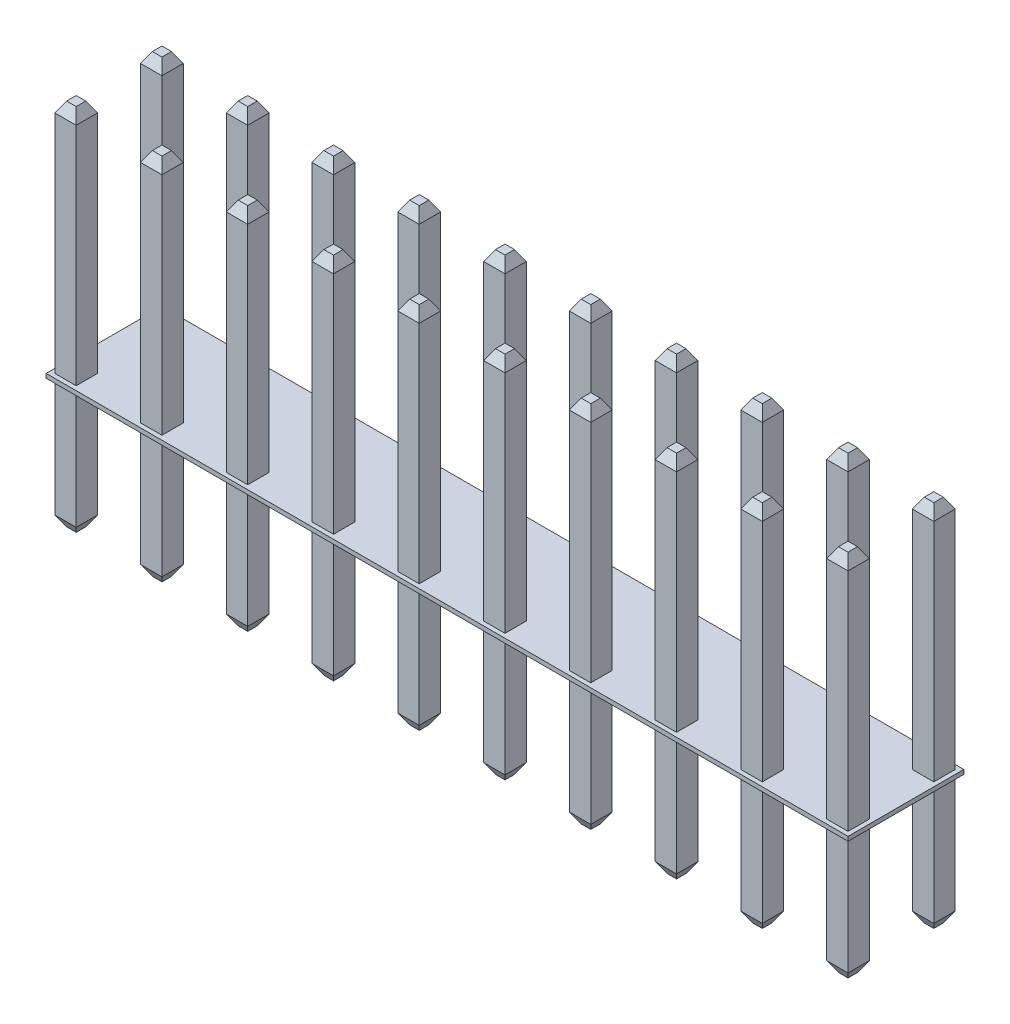
from build123d import *

# Parameters (mm, degrees)
SKETCH1_W              = 23.749
SKETCH1_H              = 3.429
BOSS_EXTRUDE1_DEPTH    = 0.127
SKETCH2_W              = 0.635
SKETCH2_H              = 0.635
BOSS_EXTRUDE2_DEPTH    = 6.985
SKETCH3_W              = 0.635
SKETCH3_H              = 0.635
BOSS_EXTRUDE3_DEPTH    = 6.985
SKETCH4_W              = 0.635
SKETCH4_H              = 0.635
BOSS_EXTRUDE4_DEPTH    = 6.985
SKETCH5_W              = 0.635
SKETCH5_H              = 0.635
BOSS_EXTRUDE5_DEPTH    = 6.985
SKETCH6_W              = 0.635
SKETCH6_H              = 0.635
BOSS_EXTRUDE6_DEPTH    = 6.985
SKETCH7_W              = 0.635
SKETCH7_H              = 0.635
BOSS_EXTRUDE7_DEPTH    = 6.985
SKETCH8_W              = 0.635
SKETCH8_H              = 0.635
BOSS_EXTRUDE8_DEPTH    = 6.985
SKETCH9_W              = 0.635
SKETCH9_H              = 0.635
BOSS_EXTRUDE9_DEPTH    = 6.985
SKETCH10_W             = 0.635
SKETCH10_H             = 0.635
BOSS_EXTRUDE10_DEPTH   = 3.81
SKETCH11_W             = 0.635
SKETCH11_H             = 0.635
BOSS_EXTRUDE11_DEPTH   = 3.81
SKETCH12_W             = 0.635
SKETCH12_H             = 0.635
BOSS_EXTRUDE12_DEPTH   = 3.81
SKETCH13_W             = 0.635
SKETCH13_H             = 0.635
BOSS_EXTRUDE13_DEPTH   = 3.81
SKETCH14_W             = 0.635
SKETCH14_H             = 0.635
BOSS_EXTRUDE14_DEPTH   = 3.81
SKETCH15_W             = 0.635
SKETCH15_H             = 0.635
BOSS_EXTRUDE15_DEPTH   = 3.81
SKETCH16_W             = 0.635
SKETCH16_H             = 0.635
BOSS_EXTRUDE16_DEPTH   = 3.81
SKETCH17_W             = 0.635
SKETCH17_H             = 0.635
BOSS_EXTRUDE17_DEPTH   = 3.81
SKETCH18_W             = 0.635
SKETCH18_H             = 0.635
BOSS_EXTRUDE18_DEPTH   = 3.81
SKETCH19_W             = 0.635
SKETCH19_H             = 0.635
BOSS_EXTRUDE19_DEPTH   = 3.81
SKETCH20_W             = 0.635
SKETCH20_H             = 0.635
BOSS_EXTRUDE20_DEPTH   = 3.81
SKETCH21_W             = 0.635
SKETCH21_H             = 0.635
BOSS_EXTRUDE21_DEPTH   = 3.81
SKETCH22_W             = 0.635
SKETCH22_H             = 0.635
BOSS_EXTRUDE22_DEPTH   = 3.81
SKETCH23_W             = 0.635
SKETCH23_H             = 0.635
BOSS_EXTRUDE23_DEPTH   = 3.81
SKETCH24_W             = 0.635
SKETCH24_H             = 0.635
BOSS_EXTRUDE24_DEPTH   = 3.81
SKETCH25_W             = 0.635
SKETCH25_H             = 0.635
BOSS_EXTRUDE25_DEPTH   = 3.81
SKETCH26_W             = 0.635
SKETCH26_H             = 0.635
BOSS_EXTRUDE26_DEPTH   = 3.81
SKETCH27_W             = 0.635
SKETCH27_H             = 0.635
BOSS_EXTRUDE27_DEPTH   = 3.81
SKETCH28_W             = 0.635
SKETCH28_H             = 0.635
BOSS_EXTRUDE28_DEPTH   = 3.81
SKETCH29_W             = 0.635
SKETCH29_H             = 0.635
BOSS_EXTRUDE29_DEPTH   = 3.81
SKETCH30_W             = 0.635
SKETCH30_H             = 0.635
BOSS_EXTRUDE30_DEPTH   = 6.985
SKETCH31_W             = 0.635
SKETCH31_H             = 0.635
BOSS_EXTRUDE31_DEPTH   = 6.985
SKETCH32_W             = 0.635
SKETCH32_H             = 0.635
BOSS_EXTRUDE32_DEPTH   = 6.985
SKETCH33_W             = 0.635
SKETCH33_H             = 0.635
BOSS_EXTRUDE33_DEPTH   = 6.985
SKETCH34_W             = 0.635
SKETCH34_H             = 0.635
BOSS_EXTRUDE34_DEPTH   = 6.985
SKETCH35_W             = 0.635
SKETCH35_H             = 0.635
BOSS_EXTRUDE35_DEPTH   = 6.985
SKETCH36_W             = 0.635
SKETCH36_H             = 0.635
BOSS_EXTRUDE36_DEPTH   = 6.985
SKETCH37_W             = 0.635
SKETCH37_H             = 0.635
BOSS_EXTRUDE37_DEPTH   = 6.985
SKETCH38_W             = 0.635
SKETCH38_H             = 0.635
BOSS_EXTRUDE38_DEPTH   = 6.985
SKETCH39_W             = 0.635
SKETCH39_H             = 0.635
BOSS_EXTRUDE39_DEPTH   = 6.985
SKETCH40_W             = 0.635
SKETCH40_H             = 0.635
BOSS_EXTRUDE40_DEPTH   = 6.985
SKETCH41_W             = 0.635
SKETCH41_H             = 0.635
BOSS_EXTRUDE41_DEPTH   = 6.985
CHAMFER1_SIZE          = 0.175976362
CHAMFER1_SIZE2         = 0.3048
CHAMFER1_PART_2_SIZE   = 0.175976362
CHAMFER1_PART_2_SIZE2  = 0.3048
CHAMFER1_PART_3_SIZE   = 0.175976362
CHAMFER1_PART_3_SIZE2  = 0.3048
CHAMFER1_PART_4_SIZE   = 0.175976362
CHAMFER1_PART_4_SIZE2  = 0.3048
CHAMFER1_PART_5_SIZE   = 0.175976362
CHAMFER1_PART_5_SIZE2  = 0.3048
CHAMFER1_PART_6_SIZE   = 0.175976362
CHAMFER1_PART_6_SIZE2  = 0.3048
CHAMFER1_PART_7_SIZE   = 0.175976362
CHAMFER1_PART_7_SIZE2  = 0.3048
CHAMFER1_PART_8_SIZE   = 0.175976362
CHAMFER1_PART_8_SIZE2  = 0.3048
CHAMFER1_PART_9_SIZE   = 0.175976362
CHAMFER1_PART_9_SIZE2  = 0.3048
CHAMFER1_PART_10_SIZE  = 0.175976362
CHAMFER1_PART_10_SIZE2 = 0.3048
CHAMFER1_PART_11_SIZE  = 0.175976362
CHAMFER1_PART_11_SIZE2 = 0.3048
CHAMFER1_PART_12_SIZE  = 0.175976362
CHAMFER1_PART_12_SIZE2 = 0.3048
CHAMFER1_PART_13_SIZE  = 0.175976362
CHAMFER1_PART_13_SIZE2 = 0.3048
CHAMFER1_PART_14_SIZE  = 0.175976362
CHAMFER1_PART_14_SIZE2 = 0.3048
CHAMFER1_PART_15_SIZE  = 0.175976362
CHAMFER1_PART_15_SIZE2 = 0.3048
CHAMFER1_PART_16_SIZE  = 0.175976362
CHAMFER1_PART_16_SIZE2 = 0.3048
CHAMFER1_PART_17_SIZE  = 0.175976362
CHAMFER1_PART_17_SIZE2 = 0.3048
CHAMFER1_PART_18_SIZE  = 0.175976362
CHAMFER1_PART_18_SIZE2 = 0.3048
CHAMFER1_PART_19_SIZE  = 0.175976362
CHAMFER1_PART_19_SIZE2 = 0.3048
CHAMFER1_PART_20_SIZE  = 0.175976362
CHAMFER1_PART_20_SIZE2 = 0.3048
CHAMFER1_PART_21_SIZE  = 0.175976362
CHAMFER1_PART_21_SIZE2 = 0.3048
CHAMFER1_PART_22_SIZE  = 0.175976362
CHAMFER1_PART_22_SIZE2 = 0.3048
CHAMFER1_PART_23_SIZE  = 0.175976362
CHAMFER1_PART_23_SIZE2 = 0.3048
CHAMFER1_PART_24_SIZE  = 0.175976362
CHAMFER1_PART_24_SIZE2 = 0.3048
CHAMFER1_PART_25_SIZE  = 0.175976362
CHAMFER1_PART_25_SIZE2 = 0.3048
CHAMFER1_PART_26_SIZE  = 0.175976362
CHAMFER1_PART_26_SIZE2 = 0.3048
CHAMFER1_PART_27_SIZE  = 0.175976362
CHAMFER1_PART_27_SIZE2 = 0.3048
CHAMFER1_PART_28_SIZE  = 0.175976362
CHAMFER1_PART_28_SIZE2 = 0.3048
CHAMFER1_PART_29_SIZE  = 0.175976362
CHAMFER1_PART_29_SIZE2 = 0.3048
CHAMFER1_PART_30_SIZE  = 0.175976362
CHAMFER1_PART_30_SIZE2 = 0.3048
CHAMFER1_PART_31_SIZE  = 0.175976362
CHAMFER1_PART_31_SIZE2 = 0.3048
CHAMFER1_PART_32_SIZE  = 0.175976362
CHAMFER1_PART_32_SIZE2 = 0.3048
CHAMFER1_PART_33_SIZE  = 0.175976362
CHAMFER1_PART_33_SIZE2 = 0.3048
CHAMFER1_PART_34_SIZE  = 0.175976362
CHAMFER1_PART_34_SIZE2 = 0.3048
CHAMFER1_PART_35_SIZE  = 0.175976362
CHAMFER1_PART_35_SIZE2 = 0.3048
CHAMFER1_PART_36_SIZE  = 0.175976362
CHAMFER1_PART_36_SIZE2 = 0.3048
CHAMFER1_PART_37_SIZE  = 0.175976362
CHAMFER1_PART_37_SIZE2 = 0.3048
CHAMFER1_PART_38_SIZE  = 0.175976362
CHAMFER1_PART_38_SIZE2 = 0.3048
CHAMFER1_PART_39_SIZE  = 0.175976362
CHAMFER1_PART_39_SIZE2 = 0.3048
CHAMFER1_PART_40_SIZE  = 0.175976362
CHAMFER1_PART_40_SIZE2 = 0.3048


with BuildPart() as part:
    # Sketch1 → Boss-Extrude1 (new body)
    with BuildSketch(Plane(origin=(0, 3.937, 0), x_dir=(1, 0, 0), z_dir=(0, 1, 0))):
        Rectangle(SKETCH1_W, SKETCH1_H)
    extrude(amount=-BOSS_EXTRUDE1_DEPTH)

    # Sketch2 → Boss-Extrude2 (add)
    with BuildSketch(Plane(origin=(0, 3.937, 0), x_dir=(-1, 0, 0), z_dir=(0, 1, 0))):
        with Locations((8.89, -1.27)):
            Rectangle(SKETCH2_W, SKETCH2_H)
    extrude(amount=BOSS_EXTRUDE2_DEPTH)

    # Sketch3 → Boss-Extrude3 (add)
    with BuildSketch(Plane(origin=(0, 3.937, 0), x_dir=(-1, 0, 0), z_dir=(0, 1, 0))):
        with Locations((6.35, -1.27)):
            Rectangle(SKETCH3_W, SKETCH3_H)
    extrude(amount=BOSS_EXTRUDE3_DEPTH)

    # Sketch4 → Boss-Extrude4 (add)
    with BuildSketch(Plane(origin=(0, 3.937, 0), x_dir=(-1, 0, 0), z_dir=(0, 1, 0))):
        with Locations((3.81, -1.27)):
            Rectangle(SKETCH4_W, SKETCH4_H)
    extrude(amount=BOSS_EXTRUDE4_DEPTH)

    # Sketch5 → Boss-Extrude5 (add)
    with BuildSketch(Plane(origin=(0, 3.937, 0), x_dir=(-1, 0, 0), z_dir=(0, 1, 0))):
        with Locations((1.27, -1.27)):
            Rectangle(SKETCH5_W, SKETCH5_H)
    extrude(amount=BOSS_EXTRUDE5_DEPTH)

    # Sketch6 → Boss-Extrude6 (add)
    with BuildSketch(Plane(origin=(0, 3.937, 0), x_dir=(-1, 0, 0), z_dir=(0, 1, 0))):
        with Locations((-1.27, -1.27)):
            Rectangle(SKETCH6_W, SKETCH6_H)
    extrude(amount=BOSS_EXTRUDE6_DEPTH)

    # Sketch7 → Boss-Extrude7 (add)
    with BuildSketch(Plane(origin=(0, 3.937, 0), x_dir=(-1, 0, 0), z_dir=(0, 1, 0))):
        with Locations((-3.81, -1.27)):
            Rectangle(SKETCH7_W, SKETCH7_H)
    extrude(amount=BOSS_EXTRUDE7_DEPTH)

    # Sketch8 → Boss-Extrude8 (add)
    with BuildSketch(Plane(origin=(0, 3.937, 0), x_dir=(-1, 0, 0), z_dir=(0, 1, 0))):
        with Locations((-6.35, -1.27)):
            Rectangle(SKETCH8_W, SKETCH8_H)
    extrude(amount=BOSS_EXTRUDE8_DEPTH)

    # Sketch9 → Boss-Extrude9 (add)
    with BuildSketch(Plane(origin=(0, 3.937, 0), x_dir=(-1, 0, 0), z_dir=(0, 1, 0))):
        with Locations((-8.89, -1.27)):
            Rectangle(SKETCH9_W, SKETCH9_H)
    extrude(amount=BOSS_EXTRUDE9_DEPTH)

    # Sketch10 → Boss-Extrude10 (add)
    with BuildSketch(Plane.XZ.offset(-3.81)):
        with Locations((11.43, -1.27)):
            Rectangle(SKETCH10_W, SKETCH10_H)
    extrude(amount=BOSS_EXTRUDE10_DEPTH)

    # Sketch11 → Boss-Extrude11 (add)
    with BuildSketch(Plane.XZ.offset(-3.81)):
        with Locations((8.89, -1.27)):
            Rectangle(SKETCH11_W, SKETCH11_H)
    extrude(amount=BOSS_EXTRUDE11_DEPTH)

    # Sketch12 → Boss-Extrude12 (add)
    with BuildSketch(Plane.XZ.offset(-3.81)):
        with Locations((6.35, -1.27)):
            Rectangle(SKETCH12_W, SKETCH12_H)
    extrude(amount=BOSS_EXTRUDE12_DEPTH)

    # Sketch13 → Boss-Extrude13 (add)
    with BuildSketch(Plane.XZ.offset(-3.81)):
        with Locations((3.81, -1.27)):
            Rectangle(SKETCH13_W, SKETCH13_H)
    extrude(amount=BOSS_EXTRUDE13_DEPTH)

    # Sketch14 → Boss-Extrude14 (add)
    with BuildSketch(Plane.XZ.offset(-3.81)):
        with Locations((1.27, -1.27)):
            Rectangle(SKETCH14_W, SKETCH14_H)
    extrude(amount=BOSS_EXTRUDE14_DEPTH)

    # Sketch15 → Boss-Extrude15 (add)
    with BuildSketch(Plane.XZ.offset(-3.81)):
        with Locations((-1.27, -1.27)):
            Rectangle(SKETCH15_W, SKETCH15_H)
    extrude(amount=BOSS_EXTRUDE15_DEPTH)

    # Sketch16 → Boss-Extrude16 (add)
    with BuildSketch(Plane.XZ.offset(-3.81)):
        with Locations((-3.81, -1.27)):
            Rectangle(SKETCH16_W, SKETCH16_H)
    extrude(amount=BOSS_EXTRUDE16_DEPTH)

    # Sketch17 → Boss-Extrude17 (add)
    with BuildSketch(Plane.XZ.offset(-3.81)):
        with Locations((-6.35, -1.27)):
            Rectangle(SKETCH17_W, SKETCH17_H)
    extrude(amount=BOSS_EXTRUDE17_DEPTH)

    # Sketch18 → Boss-Extrude18 (add)
    with BuildSketch(Plane.XZ.offset(-3.81)):
        with Locations((-8.89, -1.27)):
            Rectangle(SKETCH18_W, SKETCH18_H)
    extrude(amount=BOSS_EXTRUDE18_DEPTH)

    # Sketch19 → Boss-Extrude19 (add)
    with BuildSketch(Plane.XZ.offset(-3.81)):
        with Locations((-11.43, -1.27)):
            Rectangle(SKETCH19_W, SKETCH19_H)
    extrude(amount=BOSS_EXTRUDE19_DEPTH)

    # Sketch20 → Boss-Extrude20 (add)
    with BuildSketch(Plane.XZ.offset(-3.81)):
        with Locations((-11.43, 1.27)):
            Rectangle(SKETCH20_W, SKETCH20_H)
    extrude(amount=BOSS_EXTRUDE20_DEPTH)

    # Sketch21 → Boss-Extrude21 (add)
    with BuildSketch(Plane.XZ.offset(-3.81)):
        with Locations((-8.89, 1.27)):
            Rectangle(SKETCH21_W, SKETCH21_H)
    extrude(amount=BOSS_EXTRUDE21_DEPTH)

    # Sketch22 → Boss-Extrude22 (add)
    with BuildSketch(Plane.XZ.offset(-3.81)):
        with Locations((-6.35, 1.27)):
            Rectangle(SKETCH22_W, SKETCH22_H)
    extrude(amount=BOSS_EXTRUDE22_DEPTH)

    # Sketch23 → Boss-Extrude23 (add)
    with BuildSketch(Plane.XZ.offset(-3.81)):
        with Locations((-3.81, 1.27)):
            Rectangle(SKETCH23_W, SKETCH23_H)
    extrude(amount=BOSS_EXTRUDE23_DEPTH)

    # Sketch24 → Boss-Extrude24 (add)
    with BuildSketch(Plane.XZ.offset(-3.81)):
        with Locations((-1.27, 1.27)):
            Rectangle(SKETCH24_W, SKETCH24_H)
    extrude(amount=BOSS_EXTRUDE24_DEPTH)

    # Sketch25 → Boss-Extrude25 (add)
    with BuildSketch(Plane.XZ.offset(-3.81)):
        with Locations((1.27, 1.27)):
            Rectangle(SKETCH25_W, SKETCH25_H)
    extrude(amount=BOSS_EXTRUDE25_DEPTH)

    # Sketch26 → Boss-Extrude26 (add)
    with BuildSketch(Plane.XZ.offset(-3.81)):
        with Locations((3.81, 1.27)):
            Rectangle(SKETCH26_W, SKETCH26_H)
    extrude(amount=BOSS_EXTRUDE26_DEPTH)

    # Sketch27 → Boss-Extrude27 (add)
    with BuildSketch(Plane.XZ.offset(-3.81)):
        with Locations((6.35, 1.27)):
            Rectangle(SKETCH27_W, SKETCH27_H)
    extrude(amount=BOSS_EXTRUDE27_DEPTH)

    # Sketch28 → Boss-Extrude28 (add)
    with BuildSketch(Plane.XZ.offset(-3.81)):
        with Locations((8.89, 1.27)):
            Rectangle(SKETCH28_W, SKETCH28_H)
    extrude(amount=BOSS_EXTRUDE28_DEPTH)

    # Sketch29 → Boss-Extrude29 (add)
    with BuildSketch(Plane.XZ.offset(-3.81)):
        with Locations((11.43, 1.27)):
            Rectangle(SKETCH29_W, SKETCH29_H)
    extrude(amount=BOSS_EXTRUDE29_DEPTH)

    # Sketch30 → Boss-Extrude30 (add)
    with BuildSketch(Plane(origin=(0, 3.937, 0), x_dir=(-1, 0, 0), z_dir=(0, 1, 0))):
        with Locations((-11.43, 1.27)):
            Rectangle(SKETCH30_W, SKETCH30_H)
    extrude(amount=BOSS_EXTRUDE30_DEPTH)

    # Sketch31 → Boss-Extrude31 (add)
    with BuildSketch(Plane(origin=(0, 3.937, 0), x_dir=(-1, 0, 0), z_dir=(0, 1, 0))):
        with Locations((-8.89, 1.27)):
            Rectangle(SKETCH31_W, SKETCH31_H)
    extrude(amount=BOSS_EXTRUDE31_DEPTH)

    # Sketch32 → Boss-Extrude32 (add)
    with BuildSketch(Plane(origin=(0, 3.937, 0), x_dir=(-1, 0, 0), z_dir=(0, 1, 0))):
        with Locations((-6.35, 1.27)):
            Rectangle(SKETCH32_W, SKETCH32_H)
    extrude(amount=BOSS_EXTRUDE32_DEPTH)

    # Sketch33 → Boss-Extrude33 (add)
    with BuildSketch(Plane(origin=(0, 3.937, 0), x_dir=(-1, 0, 0), z_dir=(0, 1, 0))):
        with Locations((-3.81, 1.27)):
            Rectangle(SKETCH33_W, SKETCH33_H)
    extrude(amount=BOSS_EXTRUDE33_DEPTH)

    # Sketch34 → Boss-Extrude34 (add)
    with BuildSketch(Plane(origin=(0, 3.937, 0), x_dir=(-1, 0, 0), z_dir=(0, 1, 0))):
        with Locations((-1.27, 1.27)):
            Rectangle(SKETCH34_W, SKETCH34_H)
    extrude(amount=BOSS_EXTRUDE34_DEPTH)

    # Sketch35 → Boss-Extrude35 (add)
    with BuildSketch(Plane(origin=(0, 3.937, 0), x_dir=(-1, 0, 0), z_dir=(0, 1, 0))):
        with Locations((1.27, 1.27)):
            Rectangle(SKETCH35_W, SKETCH35_H)
    extrude(amount=BOSS_EXTRUDE35_DEPTH)

    # Sketch36 → Boss-Extrude36 (add)
    with BuildSketch(Plane(origin=(0, 3.937, 0), x_dir=(-1, 0, 0), z_dir=(0, 1, 0))):
        with Locations((3.81, 1.27)):
            Rectangle(SKETCH36_W, SKETCH36_H)
    extrude(amount=BOSS_EXTRUDE36_DEPTH)

    # Sketch37 → Boss-Extrude37 (add)
    with BuildSketch(Plane(origin=(0, 3.937, 0), x_dir=(-1, 0, 0), z_dir=(0, 1, 0))):
        with Locations((6.35, 1.27)):
            Rectangle(SKETCH37_W, SKETCH37_H)
    extrude(amount=BOSS_EXTRUDE37_DEPTH)

    # Sketch38 → Boss-Extrude38 (add)
    with BuildSketch(Plane(origin=(0, 3.937, 0), x_dir=(-1, 0, 0), z_dir=(0, 1, 0))):
        with Locations((8.89, 1.27)):
            Rectangle(SKETCH38_W, SKETCH38_H)
    extrude(amount=BOSS_EXTRUDE38_DEPTH)

    # Sketch39 → Boss-Extrude39 (add)
    with BuildSketch(Plane(origin=(0, 3.937, 0), x_dir=(-1, 0, 0), z_dir=(0, 1, 0))):
        with Locations((11.43, -1.27)):
            Rectangle(SKETCH39_W, SKETCH39_H)
    extrude(amount=BOSS_EXTRUDE39_DEPTH)

    # Sketch40 → Boss-Extrude40 (add)
    with BuildSketch(Plane(origin=(0, 3.937, 0), x_dir=(-1, 0, 0), z_dir=(0, 1, 0))):
        with Locations((-11.43, -1.27)):
            Rectangle(SKETCH40_W, SKETCH40_H)
    extrude(amount=BOSS_EXTRUDE40_DEPTH)

    # Sketch41 → Boss-Extrude41 (add)
    with BuildSketch(Plane(origin=(0, 3.937, 0), x_dir=(-1, 0, 0), z_dir=(0, 1, 0))):
        with Locations((11.43, 1.27)):
            Rectangle(SKETCH41_W, SKETCH41_H)
    extrude(amount=BOSS_EXTRUDE41_DEPTH)

    # Chamfer1
    chamfer1_edges = [part.edges().sort_by_distance(p)[0] for p in [
        (6.0325, 10.922, -1.27),
        (6.35, 10.922, -0.9525),
        (6.6675, 10.922, -1.27),
        (6.35, 10.922, -1.5875),
    ]]
    chamfer1_side = [part.faces().sort_by_distance(p)[0] for p in [
        (6.35, 10.922, -1.27),
    ]]
    chamfer(chamfer1_edges, length=CHAMFER1_SIZE, length2=CHAMFER1_SIZE2, reference=chamfer1_side[0])

    # Chamfer1 part 2
    chamfer1_part_2_edges = [part.edges().sort_by_distance(p)[0] for p in [
        (8.5725, 10.922, -1.27),
        (8.89, 10.922, -0.9525),
        (9.2075, 10.922, -1.27),
        (8.89, 10.922, -1.5875),
    ]]
    chamfer1_part_2_side = [part.faces().sort_by_distance(p)[0] for p in [
        (8.89, 10.922, -1.27),
    ]]
    chamfer(chamfer1_part_2_edges, length=CHAMFER1_PART_2_SIZE, length2=CHAMFER1_PART_2_SIZE2, reference=chamfer1_part_2_side[0])

    # Chamfer1 part 3
    chamfer1_part_3_edges = [part.edges().sort_by_distance(p)[0] for p in [
        (11.43, 0, -0.9525),
        (11.1125, 0, -1.27),
        (11.43, 0, -1.5875),
        (11.7475, 0, -1.27),
    ]]
    chamfer1_part_3_side = [part.faces().sort_by_distance(p)[0] for p in [
        (11.43, 0, -1.27),
    ]]
    chamfer(chamfer1_part_3_edges, length=CHAMFER1_PART_3_SIZE, length2=CHAMFER1_PART_3_SIZE2, reference=chamfer1_part_3_side[0])

    # Chamfer1 part 4
    chamfer1_part_4_edges = [part.edges().sort_by_distance(p)[0] for p in [
        (9.2075, 0, -1.27),
        (8.89, 0, -0.9525),
        (8.5725, 0, -1.27),
        (8.89, 0, -1.5875),
    ]]
    chamfer1_part_4_side = [part.faces().sort_by_distance(p)[0] for p in [
        (8.89, 0, -1.27),
    ]]
    chamfer(chamfer1_part_4_edges, length=CHAMFER1_PART_4_SIZE, length2=CHAMFER1_PART_4_SIZE2, reference=chamfer1_part_4_side[0])

    # Chamfer1 part 5
    chamfer1_part_5_edges = [part.edges().sort_by_distance(p)[0] for p in [
        (6.6675, 0, -1.27),
        (6.35, 0, -0.9525),
        (6.0325, 0, -1.27),
        (6.35, 0, -1.5875),
    ]]
    chamfer1_part_5_side = [part.faces().sort_by_distance(p)[0] for p in [
        (6.35, 0, -1.27),
    ]]
    chamfer(chamfer1_part_5_edges, length=CHAMFER1_PART_5_SIZE, length2=CHAMFER1_PART_5_SIZE2, reference=chamfer1_part_5_side[0])

    # Chamfer1 part 6
    chamfer1_part_6_edges = [part.edges().sort_by_distance(p)[0] for p in [
        (4.1275, 0, -1.27),
        (3.81, 0, -0.9525),
        (3.4925, 0, -1.27),
        (3.81, 0, -1.5875),
    ]]
    chamfer1_part_6_side = [part.faces().sort_by_distance(p)[0] for p in [
        (3.81, 0, -1.27),
    ]]
    chamfer(chamfer1_part_6_edges, length=CHAMFER1_PART_6_SIZE, length2=CHAMFER1_PART_6_SIZE2, reference=chamfer1_part_6_side[0])

    # Chamfer1 part 7
    chamfer1_part_7_edges = [part.edges().sort_by_distance(p)[0] for p in [
        (-8.89, 10.922, -0.9525),
        (-8.5725, 10.922, -1.27),
        (-8.89, 10.922, -1.5875),
        (-9.2075, 10.922, -1.27),
    ]]
    chamfer1_part_7_side = [part.faces().sort_by_distance(p)[0] for p in [
        (-8.89, 10.922, -1.27),
    ]]
    chamfer(chamfer1_part_7_edges, length=CHAMFER1_PART_7_SIZE, length2=CHAMFER1_PART_7_SIZE2, reference=chamfer1_part_7_side[0])

    # Chamfer1 part 8
    chamfer1_part_8_edges = [part.edges().sort_by_distance(p)[0] for p in [
        (1.5875, 0, -1.27),
        (1.27, 0, -0.9525),
        (0.9525, 0, -1.27),
        (1.27, 0, -1.5875),
    ]]
    chamfer1_part_8_side = [part.faces().sort_by_distance(p)[0] for p in [
        (1.27, 0, -1.27),
    ]]
    chamfer(chamfer1_part_8_edges, length=CHAMFER1_PART_8_SIZE, length2=CHAMFER1_PART_8_SIZE2, reference=chamfer1_part_8_side[0])

    # Chamfer1 part 9
    chamfer1_part_9_edges = [part.edges().sort_by_distance(p)[0] for p in [
        (-0.9525, 0, -1.27),
        (-1.27, 0, -0.9525),
        (-1.5875, 0, -1.27),
        (-1.27, 0, -1.5875),
    ]]
    chamfer1_part_9_side = [part.faces().sort_by_distance(p)[0] for p in [
        (-1.27, 0, -1.27),
    ]]
    chamfer(chamfer1_part_9_edges, length=CHAMFER1_PART_9_SIZE, length2=CHAMFER1_PART_9_SIZE2, reference=chamfer1_part_9_side[0])

    # Chamfer1 part 10
    chamfer1_part_10_edges = [part.edges().sort_by_distance(p)[0] for p in [
        (-3.4925, 0, -1.27),
        (-3.81, 0, -0.9525),
        (-4.1275, 0, -1.27),
        (-3.81, 0, -1.5875),
    ]]
    chamfer1_part_10_side = [part.faces().sort_by_distance(p)[0] for p in [
        (-3.81, 0, -1.27),
    ]]
    chamfer(chamfer1_part_10_edges, length=CHAMFER1_PART_10_SIZE, length2=CHAMFER1_PART_10_SIZE2, reference=chamfer1_part_10_side[0])

    # Chamfer1 part 11
    chamfer1_part_11_edges = [part.edges().sort_by_distance(p)[0] for p in [
        (-6.0325, 0, -1.27),
        (-6.35, 0, -0.9525),
        (-6.6675, 0, -1.27),
        (-6.35, 0, -1.5875),
    ]]
    chamfer1_part_11_side = [part.faces().sort_by_distance(p)[0] for p in [
        (-6.35, 0, -1.27),
    ]]
    chamfer(chamfer1_part_11_edges, length=CHAMFER1_PART_11_SIZE, length2=CHAMFER1_PART_11_SIZE2, reference=chamfer1_part_11_side[0])

    # Chamfer1 part 12
    chamfer1_part_12_edges = [part.edges().sort_by_distance(p)[0] for p in [
        (-8.5725, 0, -1.27),
        (-8.89, 0, -0.9525),
        (-9.2075, 0, -1.27),
        (-8.89, 0, -1.5875),
    ]]
    chamfer1_part_12_side = [part.faces().sort_by_distance(p)[0] for p in [
        (-8.89, 0, -1.27),
    ]]
    chamfer(chamfer1_part_12_edges, length=CHAMFER1_PART_12_SIZE, length2=CHAMFER1_PART_12_SIZE2, reference=chamfer1_part_12_side[0])

    # Chamfer1 part 13
    chamfer1_part_13_edges = [part.edges().sort_by_distance(p)[0] for p in [
        (-11.1125, 0, -1.27),
        (-11.43, 0, -0.9525),
        (-11.7475, 0, -1.27),
        (-11.43, 0, -1.5875),
    ]]
    chamfer1_part_13_side = [part.faces().sort_by_distance(p)[0] for p in [
        (-11.43, 0, -1.27),
    ]]
    chamfer(chamfer1_part_13_edges, length=CHAMFER1_PART_13_SIZE, length2=CHAMFER1_PART_13_SIZE2, reference=chamfer1_part_13_side[0])

    # Chamfer1 part 14
    chamfer1_part_14_edges = [part.edges().sort_by_distance(p)[0] for p in [
        (-11.7475, 0, 1.27),
        (-11.43, 0, 0.9525),
        (-11.1125, 0, 1.27),
        (-11.43, 0, 1.5875),
    ]]
    chamfer1_part_14_side = [part.faces().sort_by_distance(p)[0] for p in [
        (-11.43, 0, 1.27),
    ]]
    chamfer(chamfer1_part_14_edges, length=CHAMFER1_PART_14_SIZE, length2=CHAMFER1_PART_14_SIZE2, reference=chamfer1_part_14_side[0])

    # Chamfer1 part 15
    chamfer1_part_15_edges = [part.edges().sort_by_distance(p)[0] for p in [
        (-9.2075, 0, 1.27),
        (-8.89, 0, 0.9525),
        (-8.5725, 0, 1.27),
        (-8.89, 0, 1.5875),
    ]]
    chamfer1_part_15_side = [part.faces().sort_by_distance(p)[0] for p in [
        (-8.89, 0, 1.27),
    ]]
    chamfer(chamfer1_part_15_edges, length=CHAMFER1_PART_15_SIZE, length2=CHAMFER1_PART_15_SIZE2, reference=chamfer1_part_15_side[0])

    # Chamfer1 part 16
    chamfer1_part_16_edges = [part.edges().sort_by_distance(p)[0] for p in [
        (-6.6675, 10.922, -1.27),
        (-6.35, 10.922, -0.9525),
        (-6.0325, 10.922, -1.27),
        (-6.35, 10.922, -1.5875),
    ]]
    chamfer1_part_16_side = [part.faces().sort_by_distance(p)[0] for p in [
        (-6.35, 10.922, -1.27),
    ]]
    chamfer(chamfer1_part_16_edges, length=CHAMFER1_PART_16_SIZE, length2=CHAMFER1_PART_16_SIZE2, reference=chamfer1_part_16_side[0])

    # Chamfer1 part 17
    chamfer1_part_17_edges = [part.edges().sort_by_distance(p)[0] for p in [
        (-6.0325, 0, 1.27),
        (-6.35, 0, 1.5875),
        (-6.6675, 0, 1.27),
        (-6.35, 0, 0.9525),
    ]]
    chamfer1_part_17_side = [part.faces().sort_by_distance(p)[0] for p in [
        (-6.35, 0, 1.27),
    ]]
    chamfer(chamfer1_part_17_edges, length=CHAMFER1_PART_17_SIZE, length2=CHAMFER1_PART_17_SIZE2, reference=chamfer1_part_17_side[0])

    # Chamfer1 part 18
    chamfer1_part_18_edges = [part.edges().sort_by_distance(p)[0] for p in [
        (-3.4925, 0, 1.27),
        (-3.81, 0, 1.5875),
        (-4.1275, 0, 1.27),
        (-3.81, 0, 0.9525),
    ]]
    chamfer1_part_18_side = [part.faces().sort_by_distance(p)[0] for p in [
        (-3.81, 0, 1.27),
    ]]
    chamfer(chamfer1_part_18_edges, length=CHAMFER1_PART_18_SIZE, length2=CHAMFER1_PART_18_SIZE2, reference=chamfer1_part_18_side[0])

    # Chamfer1 part 19
    chamfer1_part_19_edges = [part.edges().sort_by_distance(p)[0] for p in [
        (-0.9525, 0, 1.27),
        (-1.27, 0, 1.5875),
        (-1.5875, 0, 1.27),
        (-1.27, 0, 0.9525),
    ]]
    chamfer1_part_19_side = [part.faces().sort_by_distance(p)[0] for p in [
        (-1.27, 0, 1.27),
    ]]
    chamfer(chamfer1_part_19_edges, length=CHAMFER1_PART_19_SIZE, length2=CHAMFER1_PART_19_SIZE2, reference=chamfer1_part_19_side[0])

    # Chamfer1 part 20
    chamfer1_part_20_edges = [part.edges().sort_by_distance(p)[0] for p in [
        (1.5875, 0, 1.27),
        (1.27, 0, 1.5875),
        (0.9525, 0, 1.27),
        (1.27, 0, 0.9525),
    ]]
    chamfer1_part_20_side = [part.faces().sort_by_distance(p)[0] for p in [
        (1.27, 0, 1.27),
    ]]
    chamfer(chamfer1_part_20_edges, length=CHAMFER1_PART_20_SIZE, length2=CHAMFER1_PART_20_SIZE2, reference=chamfer1_part_20_side[0])

    # Chamfer1 part 21
    chamfer1_part_21_edges = [part.edges().sort_by_distance(p)[0] for p in [
        (4.1275, 0, 1.27),
        (3.81, 0, 1.5875),
        (3.4925, 0, 1.27),
        (3.81, 0, 0.9525),
    ]]
    chamfer1_part_21_side = [part.faces().sort_by_distance(p)[0] for p in [
        (3.81, 0, 1.27),
    ]]
    chamfer(chamfer1_part_21_edges, length=CHAMFER1_PART_21_SIZE, length2=CHAMFER1_PART_21_SIZE2, reference=chamfer1_part_21_side[0])

    # Chamfer1 part 22
    chamfer1_part_22_edges = [part.edges().sort_by_distance(p)[0] for p in [
        (6.6675, 0, 1.27),
        (6.35, 0, 1.5875),
        (6.0325, 0, 1.27),
        (6.35, 0, 0.9525),
    ]]
    chamfer1_part_22_side = [part.faces().sort_by_distance(p)[0] for p in [
        (6.35, 0, 1.27),
    ]]
    chamfer(chamfer1_part_22_edges, length=CHAMFER1_PART_22_SIZE, length2=CHAMFER1_PART_22_SIZE2, reference=chamfer1_part_22_side[0])

    # Chamfer1 part 23
    chamfer1_part_23_edges = [part.edges().sort_by_distance(p)[0] for p in [
        (9.2075, 0, 1.27),
        (8.89, 0, 1.5875),
        (8.5725, 0, 1.27),
        (8.89, 0, 0.9525),
    ]]
    chamfer1_part_23_side = [part.faces().sort_by_distance(p)[0] for p in [
        (8.89, 0, 1.27),
    ]]
    chamfer(chamfer1_part_23_edges, length=CHAMFER1_PART_23_SIZE, length2=CHAMFER1_PART_23_SIZE2, reference=chamfer1_part_23_side[0])

    # Chamfer1 part 24
    chamfer1_part_24_edges = [part.edges().sort_by_distance(p)[0] for p in [
        (11.7475, 0, 1.27),
        (11.43, 0, 1.5875),
        (11.1125, 0, 1.27),
        (11.43, 0, 0.9525),
    ]]
    chamfer1_part_24_side = [part.faces().sort_by_distance(p)[0] for p in [
        (11.43, 0, 1.27),
    ]]
    chamfer(chamfer1_part_24_edges, length=CHAMFER1_PART_24_SIZE, length2=CHAMFER1_PART_24_SIZE2, reference=chamfer1_part_24_side[0])

    # Chamfer1 part 25
    chamfer1_part_25_edges = [part.edges().sort_by_distance(p)[0] for p in [
        (11.1125, 10.922, 1.27),
        (11.43, 10.922, 1.5875),
        (11.7475, 10.922, 1.27),
        (11.43, 10.922, 0.9525),
    ]]
    chamfer1_part_25_side = [part.faces().sort_by_distance(p)[0] for p in [
        (11.43, 10.922, 1.27),
    ]]
    chamfer(chamfer1_part_25_edges, length=CHAMFER1_PART_25_SIZE, length2=CHAMFER1_PART_25_SIZE2, reference=chamfer1_part_25_side[0])

    # Chamfer1 part 26
    chamfer1_part_26_edges = [part.edges().sort_by_distance(p)[0] for p in [
        (8.5725, 10.922, 1.27),
        (8.89, 10.922, 1.5875),
        (9.2075, 10.922, 1.27),
        (8.89, 10.922, 0.9525),
    ]]
    chamfer1_part_26_side = [part.faces().sort_by_distance(p)[0] for p in [
        (8.89, 10.922, 1.27),
    ]]
    chamfer(chamfer1_part_26_edges, length=CHAMFER1_PART_26_SIZE, length2=CHAMFER1_PART_26_SIZE2, reference=chamfer1_part_26_side[0])

    # Chamfer1 part 27
    chamfer1_part_27_edges = [part.edges().sort_by_distance(p)[0] for p in [
        (-4.1275, 10.922, -1.27),
        (-3.81, 10.922, -0.9525),
        (-3.4925, 10.922, -1.27),
        (-3.81, 10.922, -1.5875),
    ]]
    chamfer1_part_27_side = [part.faces().sort_by_distance(p)[0] for p in [
        (-3.81, 10.922, -1.27),
    ]]
    chamfer(chamfer1_part_27_edges, length=CHAMFER1_PART_27_SIZE, length2=CHAMFER1_PART_27_SIZE2, reference=chamfer1_part_27_side[0])

    # Chamfer1 part 28
    chamfer1_part_28_edges = [part.edges().sort_by_distance(p)[0] for p in [
        (6.0325, 10.922, 1.27),
        (6.35, 10.922, 1.5875),
        (6.6675, 10.922, 1.27),
        (6.35, 10.922, 0.9525),
    ]]
    chamfer1_part_28_side = [part.faces().sort_by_distance(p)[0] for p in [
        (6.35, 10.922, 1.27),
    ]]
    chamfer(chamfer1_part_28_edges, length=CHAMFER1_PART_28_SIZE, length2=CHAMFER1_PART_28_SIZE2, reference=chamfer1_part_28_side[0])

    # Chamfer1 part 29
    chamfer1_part_29_edges = [part.edges().sort_by_distance(p)[0] for p in [
        (3.4925, 10.922, 1.27),
        (3.81, 10.922, 1.5875),
        (4.1275, 10.922, 1.27),
        (3.81, 10.922, 0.9525),
    ]]
    chamfer1_part_29_side = [part.faces().sort_by_distance(p)[0] for p in [
        (3.81, 10.922, 1.27),
    ]]
    chamfer(chamfer1_part_29_edges, length=CHAMFER1_PART_29_SIZE, length2=CHAMFER1_PART_29_SIZE2, reference=chamfer1_part_29_side[0])

    # Chamfer1 part 30
    chamfer1_part_30_edges = [part.edges().sort_by_distance(p)[0] for p in [
        (0.9525, 10.922, 1.27),
        (1.27, 10.922, 1.5875),
        (1.5875, 10.922, 1.27),
        (1.27, 10.922, 0.9525),
    ]]
    chamfer1_part_30_side = [part.faces().sort_by_distance(p)[0] for p in [
        (1.27, 10.922, 1.27),
    ]]
    chamfer(chamfer1_part_30_edges, length=CHAMFER1_PART_30_SIZE, length2=CHAMFER1_PART_30_SIZE2, reference=chamfer1_part_30_side[0])

    # Chamfer1 part 31
    chamfer1_part_31_edges = [part.edges().sort_by_distance(p)[0] for p in [
        (-1.5875, 10.922, 1.27),
        (-1.27, 10.922, 1.5875),
        (-0.9525, 10.922, 1.27),
        (-1.27, 10.922, 0.9525),
    ]]
    chamfer1_part_31_side = [part.faces().sort_by_distance(p)[0] for p in [
        (-1.27, 10.922, 1.27),
    ]]
    chamfer(chamfer1_part_31_edges, length=CHAMFER1_PART_31_SIZE, length2=CHAMFER1_PART_31_SIZE2, reference=chamfer1_part_31_side[0])

    # Chamfer1 part 32
    chamfer1_part_32_edges = [part.edges().sort_by_distance(p)[0] for p in [
        (-4.1275, 10.922, 1.27),
        (-3.81, 10.922, 1.5875),
        (-3.4925, 10.922, 1.27),
        (-3.81, 10.922, 0.9525),
    ]]
    chamfer1_part_32_side = [part.faces().sort_by_distance(p)[0] for p in [
        (-3.81, 10.922, 1.27),
    ]]
    chamfer(chamfer1_part_32_edges, length=CHAMFER1_PART_32_SIZE, length2=CHAMFER1_PART_32_SIZE2, reference=chamfer1_part_32_side[0])

    # Chamfer1 part 33
    chamfer1_part_33_edges = [part.edges().sort_by_distance(p)[0] for p in [
        (-6.6675, 10.922, 1.27),
        (-6.35, 10.922, 1.5875),
        (-6.0325, 10.922, 1.27),
        (-6.35, 10.922, 0.9525),
    ]]
    chamfer1_part_33_side = [part.faces().sort_by_distance(p)[0] for p in [
        (-6.35, 10.922, 1.27),
    ]]
    chamfer(chamfer1_part_33_edges, length=CHAMFER1_PART_33_SIZE, length2=CHAMFER1_PART_33_SIZE2, reference=chamfer1_part_33_side[0])

    # Chamfer1 part 34
    chamfer1_part_34_edges = [part.edges().sort_by_distance(p)[0] for p in [
        (-9.2075, 10.922, 1.27),
        (-8.89, 10.922, 1.5875),
        (-8.5725, 10.922, 1.27),
        (-8.89, 10.922, 0.9525),
    ]]
    chamfer1_part_34_side = [part.faces().sort_by_distance(p)[0] for p in [
        (-8.89, 10.922, 1.27),
    ]]
    chamfer(chamfer1_part_34_edges, length=CHAMFER1_PART_34_SIZE, length2=CHAMFER1_PART_34_SIZE2, reference=chamfer1_part_34_side[0])

    # Chamfer1 part 35
    chamfer1_part_35_edges = [part.edges().sort_by_distance(p)[0] for p in [
        (-11.7475, 10.922, -1.27),
        (-11.43, 10.922, -0.9525),
        (-11.1125, 10.922, -1.27),
        (-11.43, 10.922, -1.5875),
    ]]
    chamfer1_part_35_side = [part.faces().sort_by_distance(p)[0] for p in [
        (-11.43, 10.922, -1.27),
    ]]
    chamfer(chamfer1_part_35_edges, length=CHAMFER1_PART_35_SIZE, length2=CHAMFER1_PART_35_SIZE2, reference=chamfer1_part_35_side[0])

    # Chamfer1 part 36
    chamfer1_part_36_edges = [part.edges().sort_by_distance(p)[0] for p in [
        (11.43, 10.922, -1.5875),
        (11.1125, 10.922, -1.27),
        (11.43, 10.922, -0.9525),
        (11.7475, 10.922, -1.27),
    ]]
    chamfer1_part_36_side = [part.faces().sort_by_distance(p)[0] for p in [
        (11.43, 10.922, -1.27),
    ]]
    chamfer(chamfer1_part_36_edges, length=CHAMFER1_PART_36_SIZE, length2=CHAMFER1_PART_36_SIZE2, reference=chamfer1_part_36_side[0])

    # Chamfer1 part 37
    chamfer1_part_37_edges = [part.edges().sort_by_distance(p)[0] for p in [
        (-11.7475, 10.922, 1.27),
        (-11.43, 10.922, 1.5875),
        (-11.1125, 10.922, 1.27),
        (-11.43, 10.922, 0.9525),
    ]]
    chamfer1_part_37_side = [part.faces().sort_by_distance(p)[0] for p in [
        (-11.43, 10.922, 1.27),
    ]]
    chamfer(chamfer1_part_37_edges, length=CHAMFER1_PART_37_SIZE, length2=CHAMFER1_PART_37_SIZE2, reference=chamfer1_part_37_side[0])

    # Chamfer1 part 38
    chamfer1_part_38_edges = [part.edges().sort_by_distance(p)[0] for p in [
        (-1.5875, 10.922, -1.27),
        (-1.27, 10.922, -0.9525),
        (-0.9525, 10.922, -1.27),
        (-1.27, 10.922, -1.5875),
    ]]
    chamfer1_part_38_side = [part.faces().sort_by_distance(p)[0] for p in [
        (-1.27, 10.922, -1.27),
    ]]
    chamfer(chamfer1_part_38_edges, length=CHAMFER1_PART_38_SIZE, length2=CHAMFER1_PART_38_SIZE2, reference=chamfer1_part_38_side[0])

    # Chamfer1 part 39
    chamfer1_part_39_edges = [part.edges().sort_by_distance(p)[0] for p in [
        (0.9525, 10.922, -1.27),
        (1.27, 10.922, -0.9525),
        (1.5875, 10.922, -1.27),
        (1.27, 10.922, -1.5875),
    ]]
    chamfer1_part_39_side = [part.faces().sort_by_distance(p)[0] for p in [
        (1.27, 10.922, -1.27),
    ]]
    chamfer(chamfer1_part_39_edges, length=CHAMFER1_PART_39_SIZE, length2=CHAMFER1_PART_39_SIZE2, reference=chamfer1_part_39_side[0])

    # Chamfer1 part 40
    chamfer1_part_40_edges = [part.edges().sort_by_distance(p)[0] for p in [
        (3.4925, 10.922, -1.27),
        (3.81, 10.922, -0.9525),
        (4.1275, 10.922, -1.27),
        (3.81, 10.922, -1.5875),
    ]]
    chamfer1_part_40_side = [part.faces().sort_by_distance(p)[0] for p in [
        (3.81, 10.922, -1.27),
    ]]
    chamfer(chamfer1_part_40_edges, length=CHAMFER1_PART_40_SIZE, length2=CHAMFER1_PART_40_SIZE2, reference=chamfer1_part_40_side[0])


solid = part.part
